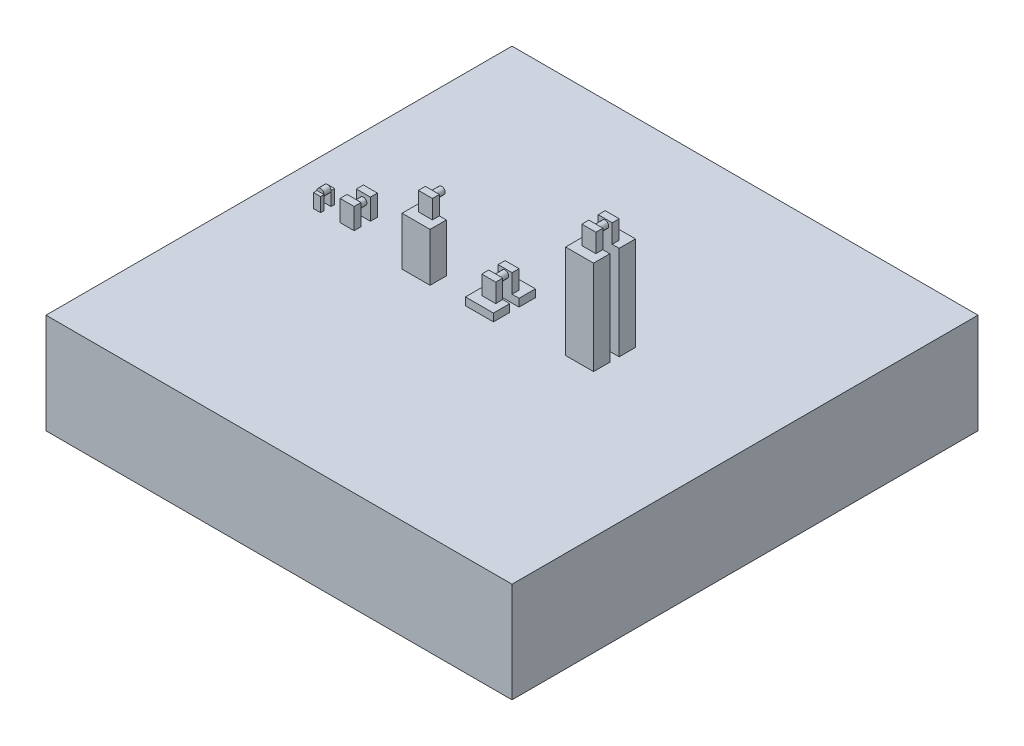
from build123d import *

# Parameters (mm, degrees)
SKETCH_1_W             = 100
SKETCH_1_H             = 100
EXTRUDE_1_DEPTH        = 1.5
EXTRUDE_1_DEPTH_BACK   = 20
SKETCH_2_R             = 0.75
EXTRUDE_2_DEPTH        = 0.75
SKETCH_3_W             = 1.5
SKETCH_3_H             = 3
EXTRUDE_3_DEPTH        = 1.5
SKETCH_5_W             = 3
SKETCH_5_H             = 1.5
EXTRUDE_4_DEPTH        = 3
SKETCH_7_R             = 0.75
EXTRUDE_5_DEPTH        = 2.5
SKETCH_8_W             = 6
SKETCH_8_H             = 9
EXTRUDE_6_DEPTH        = 10.4
SKETCH_9_W             = 3
SKETCH_9_H             = 1.5
EXTRUDE_7_DEPTH        = 4
SKETCH_10_R            = 0.75
EXTRUDE_8_DEPTH        = 3
SKETCH_11_W            = 6
SKETCH_11_H            = 2
CUT_EXTRUDE_1_DEPTH    = 10.4
SKETCH_12_W            = 6
SKETCH_12_H            = 3.5
EXTRUDE_9_DEPTH        = 20.17
SKETCH_13_W            = 3
SKETCH_13_H            = 1.5
EXTRUDE_10_DEPTH       = 4
SKETCH_14_R            = 0.75
EXTRUDE_11_DEPTH       = 2
PATTERN_LINEAR_2_COUNT = 2
PATTERN_LINEAR_2_PITCH = 13.6
SKETCH_16_W            = 6
SKETCH_16_H            = 8.75
CUT_EXTRUDE_2_DEPTH    = 9.25
SKETCH_17_W            = 6
SKETCH_17_H            = 2
CUT_EXTRUDE_3_DEPTH    = 1.65
SKETCH_18_W            = 3
SKETCH_18_H            = 1.5
EXTRUDE_12_DEPTH       = 4
SKETCH_19_R            = 0.75
EXTRUDE_13_DEPTH       = 3
EXTRUDE_14_DEPTH       = 1.5
SKETCH_21_W            = 0.75
SKETCH_21_H            = 3
CUT_EXTRUDE_4_DEPTH    = 1.5
SKETCH_22_W            = 1.5
SKETCH_22_H            = 0.5
EXTRUDE_15_DEPTH       = 2.5
SKETCH_23_W            = 3.5
SKETCH_23_H            = 14.4
CUT_EXTRUDE_5_DEPTH    = 6


with BuildPart() as part:
    # 草圖1 → 填料-伸長1 (new body, two sides)
    with BuildSketch(Plane(origin=(0, 0, 0), x_dir=(1, 0, 0), z_dir=(0, 1, 0))) as extrude_1_sk:
        Rectangle(SKETCH_1_W, SKETCH_1_H)
    extrude(amount=EXTRUDE_1_DEPTH)
    extrude(extrude_1_sk.sketch, amount=-EXTRUDE_1_DEPTH_BACK)



with BuildPart() as body_2:
    # 草圖2 → 填料-伸長2 (new body, symmetric)
    with BuildSketch(Plane.XY):
        with Locations((-40.336831864, 4.5)):
            Circle(SKETCH_2_R)
    extrude(amount=EXTRUDE_2_DEPTH, both=True)


with BuildPart() as part_1:
    add(part.part)

    add(body_2.part)  # 填料-伸長3 merges body 2
    # 草圖3 → 填料-伸長3 (add)
    with BuildSketch(Plane.XY.offset(0.75)):
        with Locations((-40.336831864, 3)):
            Rectangle(SKETCH_3_W, SKETCH_3_H)
    extrude_3 = extrude(amount=EXTRUDE_3_DEPTH)

    # 鏡射1: 填料-伸長3 across plane
    add(extrude_3.mirror(Plane.XY))

    # 草圖5 → 填料-伸長4 (add)
    with BuildSketch(Plane(origin=(0, 4.5, 0), x_dir=(1, 0, 0), z_dir=(0, 1, 0))):
        with Locations((-34.136831864, -0.5)):
            Rectangle(SKETCH_5_W, SKETCH_5_H)
        with Locations((-34.136831864, 3)):
            Rectangle(SKETCH_5_W, SKETCH_5_H)
    extrude(amount=-EXTRUDE_4_DEPTH)

    # 草圖7 → 填料-伸長5 (add)
    with BuildSketch(Plane.XY.offset(-2.25)):
        with Locations((-34.136831864, 4.5)):
            Circle(SKETCH_7_R)
    extrude(amount=EXTRUDE_5_DEPTH)

    # 草圖8 → 填料-伸長6 (add)
    with BuildSketch(Plane(origin=(0, 1.5, 0), x_dir=(1, 0, 0), z_dir=(0, 1, 0))):
        with Locations((-17.336831864, 1.25)):
            Rectangle(SKETCH_8_W, SKETCH_8_H)
    extrude_6 = extrude(amount=EXTRUDE_6_DEPTH)

    # 草圖9 → 填料-伸長7 (add)
    with BuildSketch(Plane(origin=(0, 11.9, 0), x_dir=(1, 0, 0), z_dir=(0, 1, 0))):
        with Locations((-17.336831864, 3)):
            Rectangle(SKETCH_9_W, SKETCH_9_H)
        with Locations((-17.336831864, -0.5)):
            Rectangle(SKETCH_9_W, SKETCH_9_H)
    extrude(amount=EXTRUDE_7_DEPTH)

    # 草圖10 → 填料-伸長8 (add)
    with BuildSketch(Plane.XY.offset(-2.25)):
        with Locations((-17.336831864, 14.9)):
            Circle(SKETCH_10_R)
    extrude(amount=EXTRUDE_8_DEPTH)

    # 草圖11 → 除料-伸長1 (cut)
    with BuildSketch(Plane(origin=(0, 11.9, 0), x_dir=(1, 0, 0), z_dir=(0, 1, 0))):
        with Locations((-17.336831864, 1.25)):
            Rectangle(SKETCH_11_W, SKETCH_11_H)
    extrude(amount=-CUT_EXTRUDE_1_DEPTH, mode=Mode.SUBTRACT)

    # 草圖12 → 填料-伸長9 (add)
    with BuildSketch(Plane(origin=(0, 1.5, 0), x_dir=(1, 0, 0), z_dir=(0, 1, 0))):
        with Locations((16.243168136, 0)):
            Rectangle(SKETCH_12_W, SKETCH_12_H)
        with Locations((16.243168136, 5.5)):
            Rectangle(SKETCH_12_W, SKETCH_12_H)
    extrude(amount=EXTRUDE_9_DEPTH)

    # 草圖13 → 填料-伸長10 (add)
    with BuildSketch(Plane(origin=(0, 21.67, 0), x_dir=(1, 0, 0), z_dir=(0, 1, 0))):
        with Locations((16.243168136, 1)):
            Rectangle(SKETCH_13_W, SKETCH_13_H)
        with Locations((16.243168136, 4.5)):
            Rectangle(SKETCH_13_W, SKETCH_13_H)
    extrude(amount=EXTRUDE_10_DEPTH)

    # 草圖14 → 填料-伸長11 (add)
    with BuildSketch(Plane.XY.offset(-3.75)):
        with Locations((16.243168136, 24.67)):
            Circle(SKETCH_14_R)
    extrude(amount=EXTRUDE_11_DEPTH)

    # 直線複製排列2: 填料-伸長6 ×2
    with Locations(*[(i * PATTERN_LINEAR_2_PITCH, 0, 0) for i in range(1, PATTERN_LINEAR_2_COUNT)]):
        add(extrude_6)

    # 草圖16 → 除料-伸長2 (cut, symmetric)
    with BuildSketch(Plane.XY):
        with Locations((-3.736831864, 7.525)):
            Rectangle(SKETCH_16_W, SKETCH_16_H)
    extrude(amount=CUT_EXTRUDE_2_DEPTH, both=True, mode=Mode.SUBTRACT)

    # 草圖17 → 除料-伸長3 (cut)
    with BuildSketch(Plane(origin=(0, 3.15, 0), x_dir=(1, 0, 0), z_dir=(0, 1, 0))):
        with Locations((-3.736831864, 1.25)):
            Rectangle(SKETCH_17_W, SKETCH_17_H)
    extrude(amount=-CUT_EXTRUDE_3_DEPTH, mode=Mode.SUBTRACT)

    # 草圖18 → 填料-伸長12 (add)
    with BuildSketch(Plane(origin=(0, 3.15, 0), x_dir=(1, 0, 0), z_dir=(0, 1, 0))):
        with Locations((-3.736831864, 3)):
            Rectangle(SKETCH_18_W, SKETCH_18_H)
        with Locations((-3.736831864, -0.5)):
            Rectangle(SKETCH_18_W, SKETCH_18_H)
    extrude(amount=EXTRUDE_12_DEPTH)

    # 草圖19 → 填料-伸長13 (add)
    with BuildSketch(Plane.XY.offset(-2.25)):
        with Locations((-3.736831864, 6.15)):
            Circle(SKETCH_19_R)
    extrude(amount=EXTRUDE_13_DEPTH)

    # 草圖20 → 填料-伸長14 (add)
    with BuildSketch(Plane(origin=(0, 4.5, 0), x_dir=(1, 0, 0), z_dir=(0, 1, 0))):
        Polygon((-32.636831864, 0.25), (-33.386831864, 0.25), (-33.386831864, -0.25), (-34.886831864, -0.25), (-34.886831864, 0.25), (-35.636831864, 0.25), (-35.636831864, -1.25), (-32.636831864, -1.25), align=None)
        Polygon((-35.636831864, 3.75), (-35.636831864, 2.25), (-34.886831864, 2.25), (-33.386831864, 2.25), (-32.636831864, 2.25), (-32.636831864, 3.75), align=None)
    extrude(amount=EXTRUDE_14_DEPTH)

    # 草圖21 → 除料-伸長4 (cut)
    with BuildSketch(Plane.ZY.offset(41.086831864)):
        with Locations((1.875, 3)):
            Rectangle(SKETCH_21_W, SKETCH_21_H)
        with Locations((-1.875, 3)):
            Rectangle(SKETCH_21_W, SKETCH_21_H)
    extrude(amount=-CUT_EXTRUDE_4_DEPTH, mode=Mode.SUBTRACT)

    # 草圖22 → 填料-伸長15 (add)
    with BuildSketch(Plane(origin=(0, 6, 0), x_dir=(1, 0, 0), z_dir=(0, 1, 0))):
        with Locations((-34.136831864, 0)):
            Rectangle(SKETCH_22_W, SKETCH_22_H)
    extrude(amount=-EXTRUDE_15_DEPTH)

    # 草圖23 → 除料-伸長5 (cut)
    with BuildSketch(Plane.ZY.offset(20.336831864)):
        with Locations((-4, 8.7)):
            Rectangle(SKETCH_23_W, SKETCH_23_H)
    extrude(amount=-CUT_EXTRUDE_5_DEPTH, mode=Mode.SUBTRACT)


solid = part_1.part
